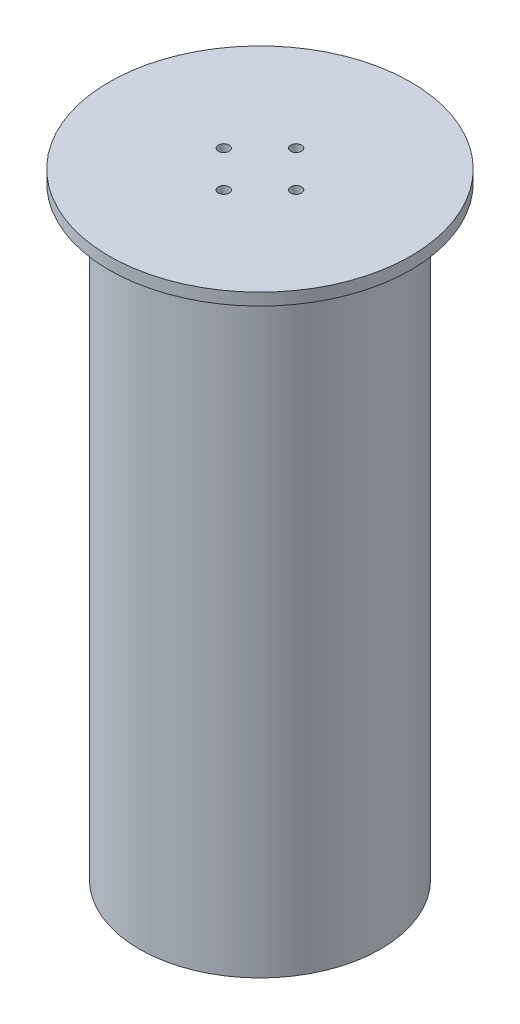
from build123d import *

# Parameters (mm, degrees)
CORTE_EXTRUS_O1_REACH = 512
ESBO_O2_R             = 4.5


with BuildPart() as part:
    # Esboço1 → Revolução1 (revolve)
    with BuildSketch(Plane.XY):
        Polygon((0, 510), (125, 510), (125, 500), (100, 500), (100, 0), (88, 0), (88, 10), (94, 10), (94, 500), (0, 500), align=None)
    revolve(axis=Axis((0, 0, 0), (0, 1, 0)))

    # Esboço2 → Corte-extrusão1 (cut, up to next)
    with BuildSketch(Plane(origin=(0, 510, 0), x_dir=(1, 0, 0), z_dir=(0, 1, 0)), mode=Mode.PRIVATE) as corte_extrus_o1_sk1:
        with Locations((0, 30)):
            Circle(ESBO_O2_R)
    corte_extrus_o1_tool1 = extrude(corte_extrus_o1_sk1.sketch, amount=-CORTE_EXTRUS_O1_REACH, mode=Mode.PRIVATE) & part.part
    add(corte_extrus_o1_tool1.solids().sort_by_distance((0, 510, -30))[0], mode=Mode.SUBTRACT)
    # Esboço2 → Corte-extrusão1 (cut, up to next)
    with BuildSketch(Plane(origin=(0, 510, 0), x_dir=(1, 0, 0), z_dir=(0, 1, 0)), mode=Mode.PRIVATE) as corte_extrus_o1_sk2:
        with Locations((30, 0)):
            Circle(ESBO_O2_R)
    corte_extrus_o1_tool2 = extrude(corte_extrus_o1_sk2.sketch, amount=-CORTE_EXTRUS_O1_REACH, mode=Mode.PRIVATE) & part.part
    add(corte_extrus_o1_tool2.solids().sort_by_distance((30, 510, 0))[0], mode=Mode.SUBTRACT)
    # Esboço2 → Corte-extrusão1 (cut, up to next)
    with BuildSketch(Plane(origin=(0, 510, 0), x_dir=(1, 0, 0), z_dir=(0, 1, 0)), mode=Mode.PRIVATE) as corte_extrus_o1_sk3:
        with Locations((0, -30)):
            Circle(ESBO_O2_R)
    corte_extrus_o1_tool3 = extrude(corte_extrus_o1_sk3.sketch, amount=-CORTE_EXTRUS_O1_REACH, mode=Mode.PRIVATE) & part.part
    add(corte_extrus_o1_tool3.solids().sort_by_distance((0, 510, 30))[0], mode=Mode.SUBTRACT)
    # Esboço2 → Corte-extrusão1 (cut, up to next)
    with BuildSketch(Plane(origin=(0, 510, 0), x_dir=(1, 0, 0), z_dir=(0, 1, 0)), mode=Mode.PRIVATE) as corte_extrus_o1_sk4:
        with Locations((-30, 0)):
            Circle(ESBO_O2_R)
    corte_extrus_o1_tool4 = extrude(corte_extrus_o1_sk4.sketch, amount=-CORTE_EXTRUS_O1_REACH, mode=Mode.PRIVATE) & part.part
    add(corte_extrus_o1_tool4.solids().sort_by_distance((-30, 510, 0))[0], mode=Mode.SUBTRACT)


solid = part.part
